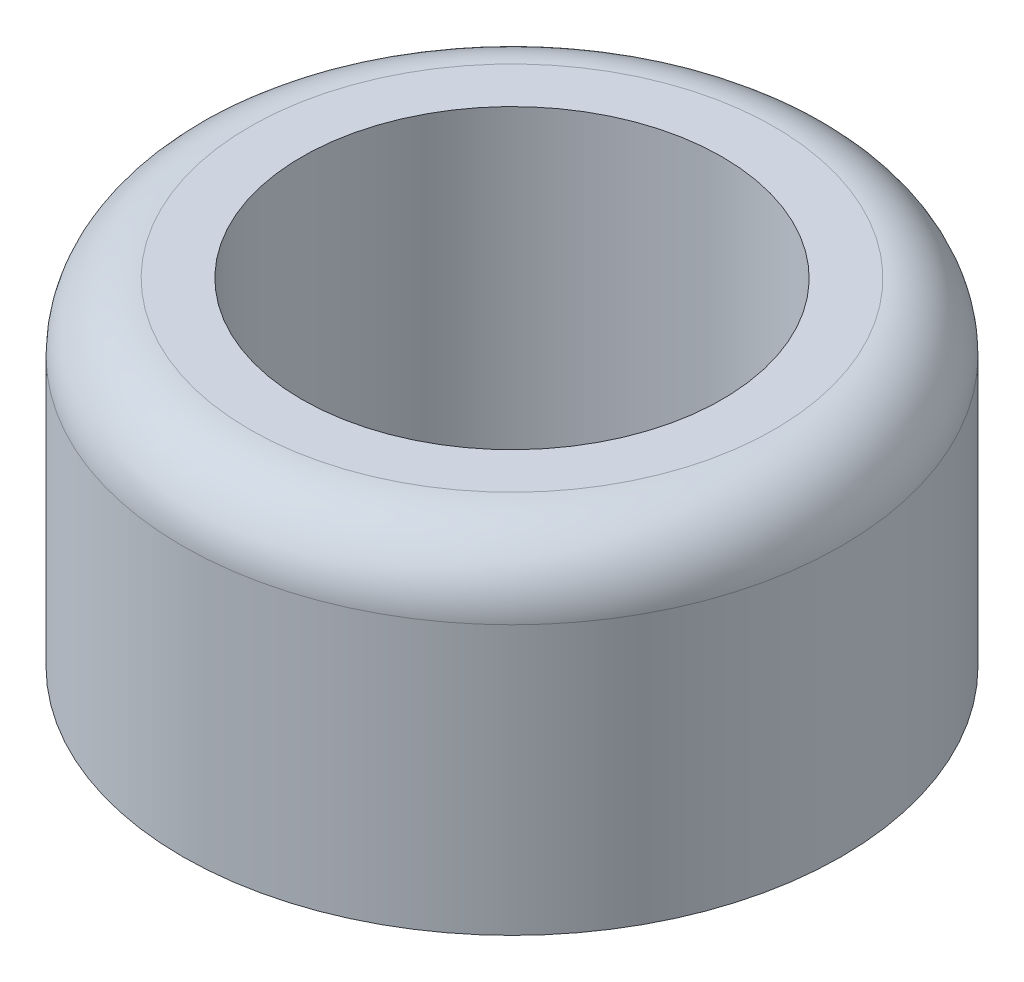
from build123d import *

# Parameters (mm, degrees)
SKETCH1_R           = 4.9
SKETCH1_R_2         = 3.125
BOSS_EXTRUDE1_DEPTH = 5
FILLET1_R           = 1


with BuildPart() as part:
    # Sketch1 → Boss-Extrude1 (new body)
    with BuildSketch(Plane(origin=(0, 0, 0), x_dir=(1, 0, 0), z_dir=(0, 1, 0))):
        Circle(SKETCH1_R)
        Circle(SKETCH1_R_2, mode=Mode.SUBTRACT)
    extrude(amount=BOSS_EXTRUDE1_DEPTH)

    # Fillet1
    fillet1_edges = [part.edges().sort_by_distance(p)[0] for p in [
        (-4.9, 5, 0),
    ]]
    fillet(fillet1_edges, radius=FILLET1_R)


solid = part.part
